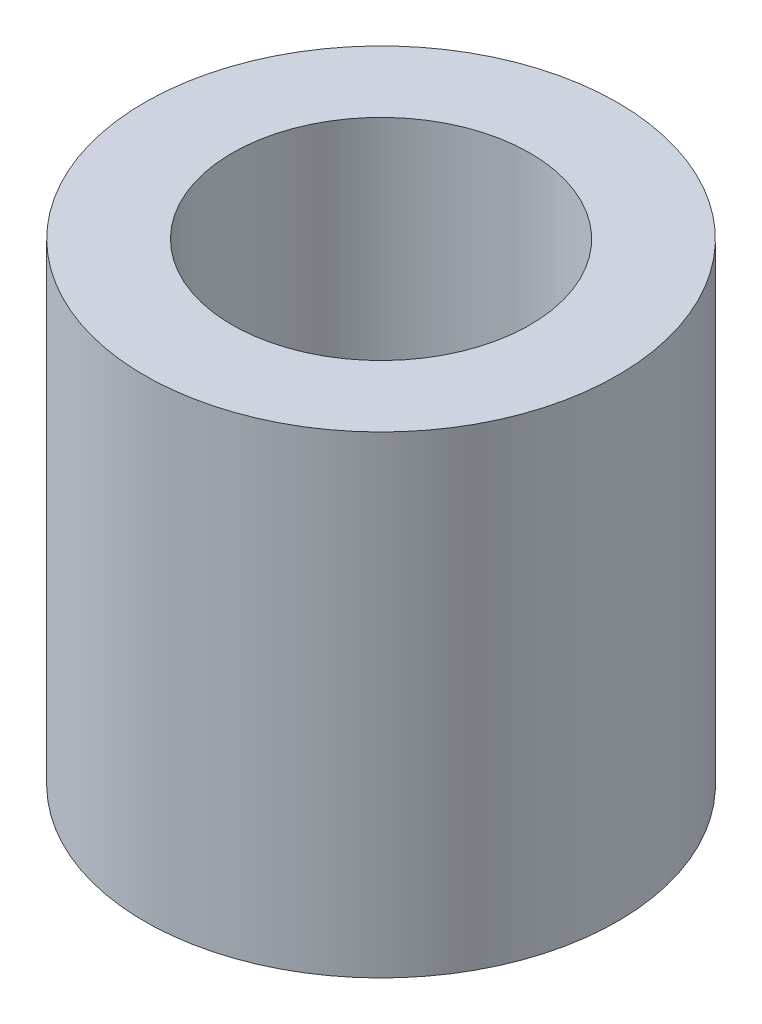
from build123d import *

# Parameters (mm, degrees)
SKETCH1_W = 1.175
SKETCH1_H = 6.35


with BuildPart() as part:
    # Sketch1 → Revolve1 (revolve)
    with BuildSketch(Plane.XY):
        with Locations((-2.5875, 3.175)):
            Rectangle(SKETCH1_W, SKETCH1_H)
    revolve(axis=Axis((0, 0, 0), (0, 1, 0)))


solid = part.part
